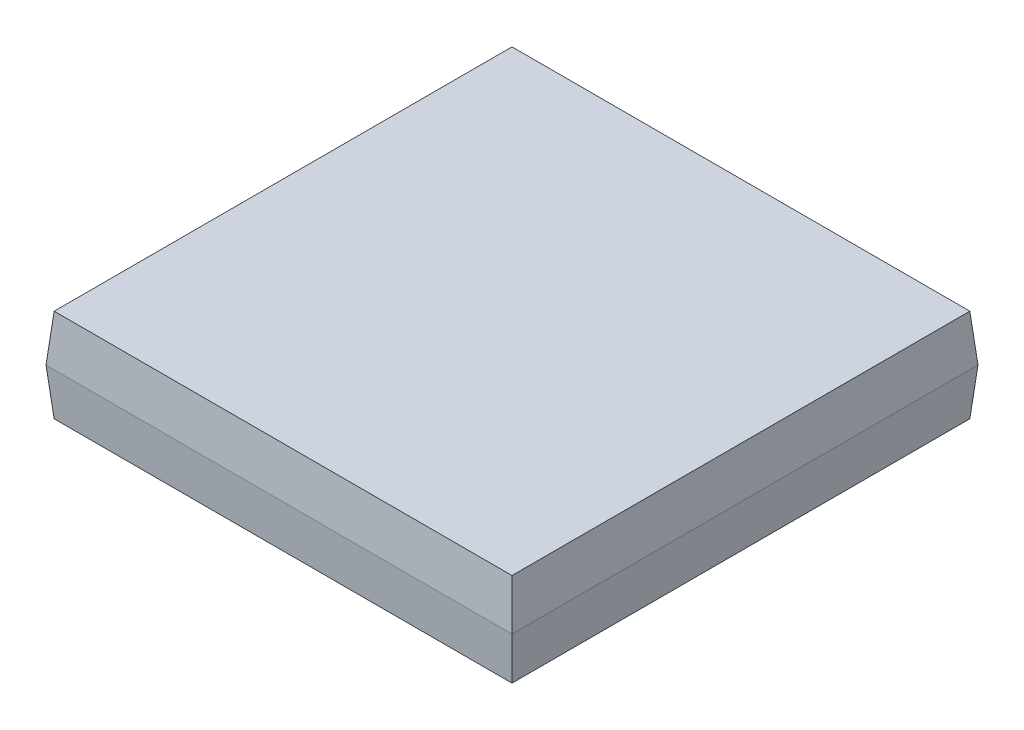
from build123d import *

# Parameters (mm, degrees)
SKETCH1_W                     = 10
SKETCH1_H                     = 10
BOSS_EXTRUDE1_DEPTH           = 1
BOSS_EXTRUDE1_TAPER           = 5
BOSS_EXTRUDE1_OTHER_WAY_DEPTH = 1
BOSS_EXTRUDE1_OTHER_WAY_TAPER = 5


with BuildPart() as part:
    # Sketch1 → Boss-Extrude1 (new body)
    with BuildSketch(Plane(origin=(0, 0, 0), x_dir=(1, 0, 0), z_dir=(0, 1, 0))):
        Rectangle(SKETCH1_W, SKETCH1_H)
    extrude(amount=BOSS_EXTRUDE1_DEPTH, taper=BOSS_EXTRUDE1_TAPER)

    # Sketch1 → Boss-Extrude1 other way (add)
    with BuildSketch(Plane(origin=(0, 0, 0), x_dir=(1, 0, 0), z_dir=(0, 1, 0))):
        Rectangle(SKETCH1_W, SKETCH1_H)
    extrude(amount=-BOSS_EXTRUDE1_OTHER_WAY_DEPTH, taper=BOSS_EXTRUDE1_OTHER_WAY_TAPER)


solid = part.part
